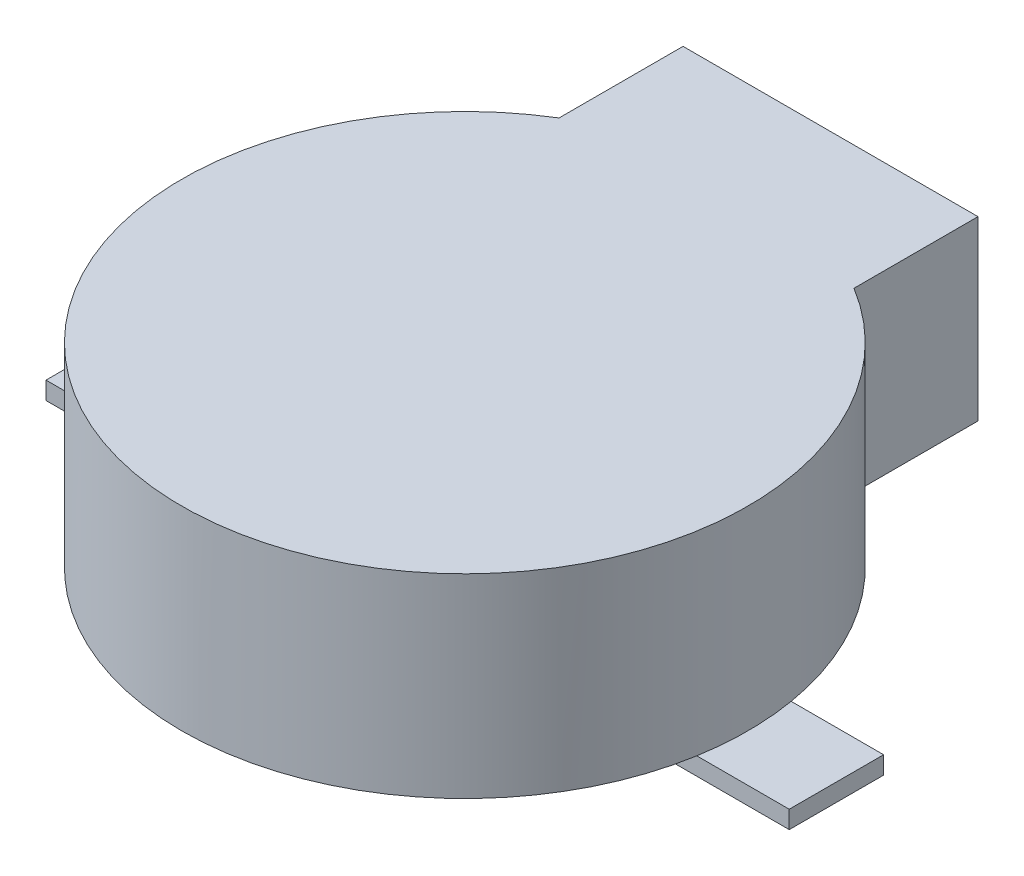
from build123d import *

# Parameters (mm, degrees)
BOSS_EXTRUDE1_DEPTH = 3.3
SKETCH2_W           = 3.5
SKETCH2_H           = 1.6
BOSS_EXTRUDE2_DEPTH = 0.3
CUT_EXTRUDE1_DEPTH  = 0.3
SKETCH4_W           = 4
SKETCH4_H           = 2
CUT_EXTRUDE2_DEPTH  = 3


with BuildPart() as part:
    # Sketch1 → Boss-Extrude1 (new body)
    with BuildSketch(Plane(origin=(0, 0, 0), x_dir=(1, 0, 0), z_dir=(0, 1, 0))):
        with BuildLine():
            Line((-2.5, 4.09756025), (-2.5, 6.2))
            Line((-2.5, 6.2), (2.5, 6.2))
            Line((2.5, 6.2), (2.5, 4.09756025))
            ThreePointArc((2.5, 4.09756025), (0, -4.8), (-2.5, 4.09756025))
        make_face()
    extrude(amount=BOSS_EXTRUDE1_DEPTH)

    # Sketch2 → Boss-Extrude2 (add)
    with BuildSketch(Plane.XZ):
        with Locations((-4.55, 0)):
            Rectangle(SKETCH2_W, SKETCH2_H)
        with Locations((4.55, 0)):
            Rectangle(SKETCH2_W, SKETCH2_H)
    extrude(amount=BOSS_EXTRUDE2_DEPTH)

    # Sketch3 → Cut-Extrude1 (cut)
    with BuildSketch(Plane.XZ):
        with BuildLine():
            Line((2.5, -4.09756025), (2.5, -6.2))
            Line((2.5, -6.2), (-2.5, -6.2))
            Line((-2.5, -6.2), (-2.5, -4.09756025))
            ThreePointArc((-2.5, -4.09756025), (0, -4.8), (2.5, -4.09756025))
        make_face()
    extrude(amount=-CUT_EXTRUDE1_DEPTH, mode=Mode.SUBTRACT)

    # Sketch4 → Cut-Extrude2 (cut)
    with BuildSketch(Plane(origin=(0, 0, -6.2), x_dir=(-1, 0, 0), z_dir=(0, 0, -1))):
        with Locations((0, 1.8)):
            Rectangle(SKETCH4_W, SKETCH4_H)
    extrude(amount=-CUT_EXTRUDE2_DEPTH, mode=Mode.SUBTRACT)


solid = part.part
